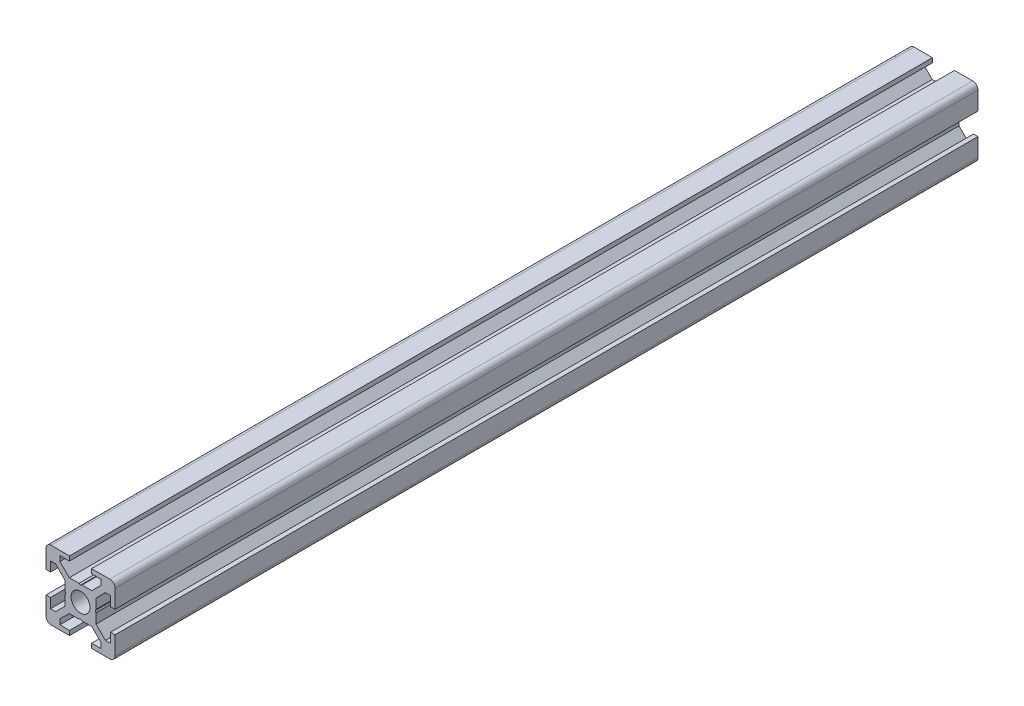
from build123d import *

# Parameters (mm, degrees)
MODEL_R             = 2.75
BOSS_EXTRUDE1_DEPTH = 250


with BuildPart() as part:
    # Model → Boss-Extrude1 (new body)
    with BuildSketch(Plane.XY):
        with BuildLine():
            Line((1.499999935, 19.99999323), (6.799999935, 19.99999323))
            Line((6.799999935, 19.99999323), (6.799999935, 18.69999323))
            Line((6.799999935, 18.69999323), (3.999999935, 18.69999323))
            Line((3.999999935, 18.69999323), (3.999999935, 17.19999323))
            Line((3.999999935, 17.19999323), (6.745762647, 14.5))
            Line((6.745762647, 14.5), (9.565216879, 14.5))
            Line((9.565216879, 14.5), (10, 14.25))
            Line((10, 14.25), (10.434782606, 14.5))
            Line((10.434782606, 14.5), (13.254244108, 14.5))
            Line((13.254244108, 14.5), (15.999999935, 17.19999323))
            Line((15.999999935, 17.19999323), (15.999999935, 18.69999323))
            Line((15.999999935, 18.69999323), (13.199999935, 18.69999323))
            Line((13.199999935, 18.69999323), (13.199999935, 19.99999323))
            Line((13.199999935, 19.99999323), (18.499999935, 19.99999323))
            ThreePointArc((18.499999935, 19.99999323), (19.560660107, 19.560653402), (19.999999935, 18.49999323))
            Line((19.999999935, 18.49999323), (19.999999935, 13.19999323))
            Line((19.999999935, 13.19999323), (18.699999935, 13.19999323))
            Line((18.699999935, 13.19999323), (18.699999935, 15.99999323))
            Line((18.699999935, 15.99999323), (17.199999935, 15.99999323))
            Line((17.199999935, 15.99999323), (14.500000065, 13.254230518))
            Line((14.500000065, 13.254230518), (14.500000065, 10.434776138))
            Line((14.500000065, 10.434776138), (14.250000065, 9.99999323))
            Line((14.250000065, 9.99999323), (14.500000065, 9.565210911))
            Line((14.500000065, 9.565210911), (14.500000065, 6.745755942))
            Line((14.500000065, 6.745755942), (17.199999935, 3.99999323))
            Line((17.199999935, 3.99999323), (18.699999935, 3.99999323))
            Line((18.699999935, 3.99999323), (18.699999935, 6.79999323))
            Line((18.699999935, 6.79999323), (19.999999935, 6.79999323))
            Line((19.999999935, 6.79999323), (19.999999935, 1.49999323))
            ThreePointArc((19.999999935, 1.49999323), (19.560660107, 0.439333058), (18.499999935, -6.77e-06))
            Line((18.499999935, -6.77e-06), (13.199999935, -6.77e-06))
            Line((13.199999935, -6.77e-06), (13.199999935, 1.29999323))
            Line((13.199999935, 1.29999323), (15.999999935, 1.29999323))
            Line((15.999999935, 1.29999323), (15.999999935, 2.798703306))
            Line((15.999999935, 2.798703306), (13.254126104, 5.49999323))
            Line((13.254126104, 5.49999323), (10.434782606, 5.49999323))
            Line((10.434782606, 5.49999323), (10, 5.74999323))
            Line((10, 5.74999323), (9.565216879, 5.49999323))
            Line((9.565216879, 5.49999323), (6.745762647, 5.49999323))
            Line((6.745762647, 5.49999323), (3.999999935, 2.79999323))
            Line((3.999999935, 2.79999323), (3.999999935, 1.29999323))
            Line((3.999999935, 1.29999323), (6.799999935, 1.29999323))
            Line((6.799999935, 1.29999323), (6.799999935, -6.77e-06))
            Line((6.799999935, -6.77e-06), (1.499999935, -6.77e-06))
            ThreePointArc((1.499999935, -6.77e-06), (0.439339764, 0.439333058), (-6.5e-08, 1.49999323))
            Line((-6.5e-08, 1.49999323), (-6.5e-08, 6.79999323))
            Line((-6.5e-08, 6.79999323), (1.299999935, 6.79999323))
            Line((1.299999935, 6.79999323), (1.299999935, 3.99999323))
            Line((1.299999935, 3.99999323), (2.799999935, 3.99999323))
            Line((2.799999935, 3.99999323), (5.499999935, 6.745755942))
            Line((5.499999935, 6.745755942), (5.499999935, 9.565210911))
            Line((5.499999935, 9.565210911), (5.749999935, 9.99999323))
            Line((5.749999935, 9.99999323), (5.499999935, 10.434776138))
            Line((5.499999935, 10.434776138), (5.499999935, 13.254230518))
            Line((5.499999935, 13.254230518), (2.799999935, 15.99999323))
            Line((2.799999935, 15.99999323), (1.299999935, 15.99999323))
            Line((1.299999935, 15.99999323), (1.299999935, 13.19999323))
            Line((1.299999935, 13.19999323), (-6.5e-08, 13.19999323))
            Line((-6.5e-08, 13.19999323), (-6.5e-08, 18.49999323))
            ThreePointArc((-6.5e-08, 18.49999323), (0.439339764, 19.560653402), (1.499999935, 19.99999323))
        make_face()
        with Locations((10, 10)):
            Circle(MODEL_R, mode=Mode.SUBTRACT)
    extrude(amount=BOSS_EXTRUDE1_DEPTH)


solid = part.part
